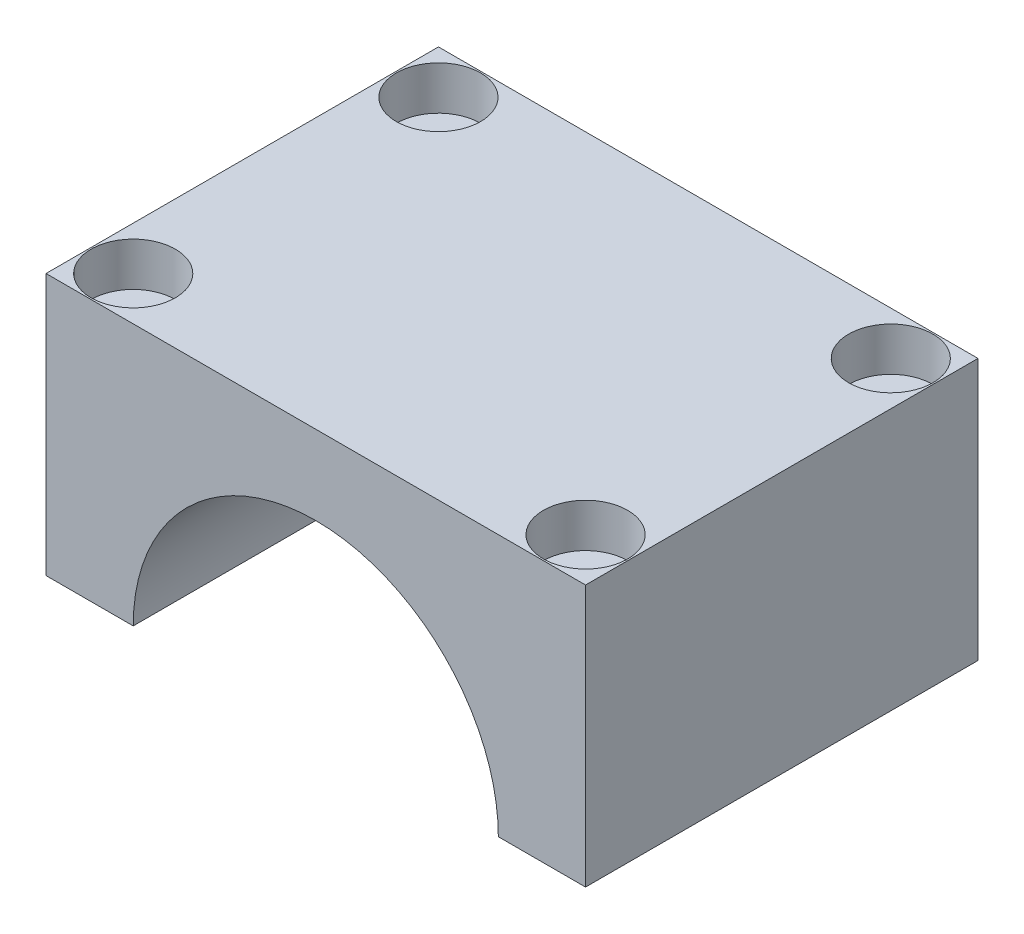
from build123d import *

# Parameters (mm, degrees)
BOSS_EXTRU_1_DEPTH      = 27
ESQUISSE5_R             = 1.3
ENL_V_MAT_EXTRU_1_DEPTH = 18
ESQUISSE6_R             = 2.9
ENL_V_MAT_EXTRU_2_DEPTH = 3


with BuildPart() as part:
    # Esquisse1 → Boss.-Extru.1 (new body)
    with BuildSketch(Plane.XY):
        with BuildLine():
            Line((-12.560062385, 0), (-18.560062385, 0))
            Line((-18.560062385, 0), (-18.560062385, 18))
            Line((-18.560062385, 18), (18.560062385, 18))
            Line((18.560062385, 18), (18.560062385, 0))
            Line((18.560062385, 0), (12.560062385, 0))
            ThreePointArc((12.560062385, 0), (0, 12.560062385), (-12.560062385, 0))
        make_face()
    extrude(amount=BOSS_EXTRU_1_DEPTH)

    # Esquisse5 → Enlèv. mat.-Extru.1 (cut)
    with BuildSketch(Plane(origin=(0, 18, 0), x_dir=(1, 0, 0), z_dir=(0, 1, 0))):
        with Locations((15.560062385, -3)):
            Circle(ESQUISSE5_R)
        with Locations((15.560062385, -24)):
            Circle(ESQUISSE5_R)
        with Locations((-15.560062385, -3)):
            Circle(ESQUISSE5_R)
        with Locations((-15.560062385, -24)):
            Circle(ESQUISSE5_R)
    extrude(amount=-ENL_V_MAT_EXTRU_1_DEPTH, mode=Mode.SUBTRACT)

    # Esquisse6 → Enlèv. mat.-Extru.2 (cut)
    with BuildSketch(Plane(origin=(0, 18, 0), x_dir=(1, 0, 0), z_dir=(0, 1, 0))):
        with Locations((15.560062385, -3)):
            Circle(ESQUISSE6_R)
        with Locations((15.560062385, -24)):
            Circle(ESQUISSE6_R)
        with Locations((-15.560062385, -3)):
            Circle(ESQUISSE6_R)
        with Locations((-15.560062385, -24)):
            Circle(ESQUISSE6_R)
    extrude(amount=-ENL_V_MAT_EXTRU_2_DEPTH, mode=Mode.SUBTRACT)


solid = part.part
